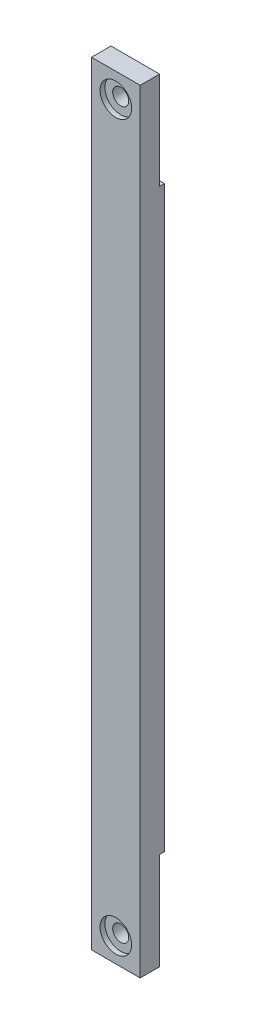
from build123d import *

# Parameters (mm, degrees)
SKETCH_1_W          = 10
SKETCH_1_H          = 159
EXTRUDE_1_DEPTH     = 5
SKETCH_3_W          = 10
SKETCH_3_H          = 20
CUT_EXTRUDE_1_DEPTH = 1
HOLE_WIZARD_M4_1_D  = 3.3
SKETCH_7_R          = 3.25
CUT_EXTRUDE_2_DEPTH = 1


with BuildPart() as part:
    # 草图1 → 凸台-拉伸1 (new body)
    with BuildSketch(Plane.XY):
        with Locations((5, -79.5)):
            Rectangle(SKETCH_1_W, SKETCH_1_H)
    extrude(amount=EXTRUDE_1_DEPTH)

    # 草图3 → 切除-拉伸1 (cut)
    with BuildSketch(Plane(origin=(0, 0, 0), x_dir=(-1, 0, 0), z_dir=(0, 0, -1))):
        with Locations((-5, -10)):
            Rectangle(SKETCH_3_W, SKETCH_3_H)
        with Locations((-5, -149)):
            Rectangle(SKETCH_3_W, SKETCH_3_H)
    extrude(amount=-CUT_EXTRUDE_1_DEPTH, mode=Mode.SUBTRACT)

    # M4 螺纹孔的螺纹孔钻头1 (through all)
    with Locations(Plane.XY.offset(5)):
        with Locations((5, -5), (5, -154)):
            Hole(HOLE_WIZARD_M4_1_D / 2)

    # 草图7 → 切除-拉伸2 (cut)
    with BuildSketch(Plane.XY.offset(5)):
        with Locations((5, -5)):
            Circle(SKETCH_7_R)
        with Locations((5, -154)):
            Circle(SKETCH_7_R)
    extrude(amount=-CUT_EXTRUDE_2_DEPTH, mode=Mode.SUBTRACT)


solid = part.part
